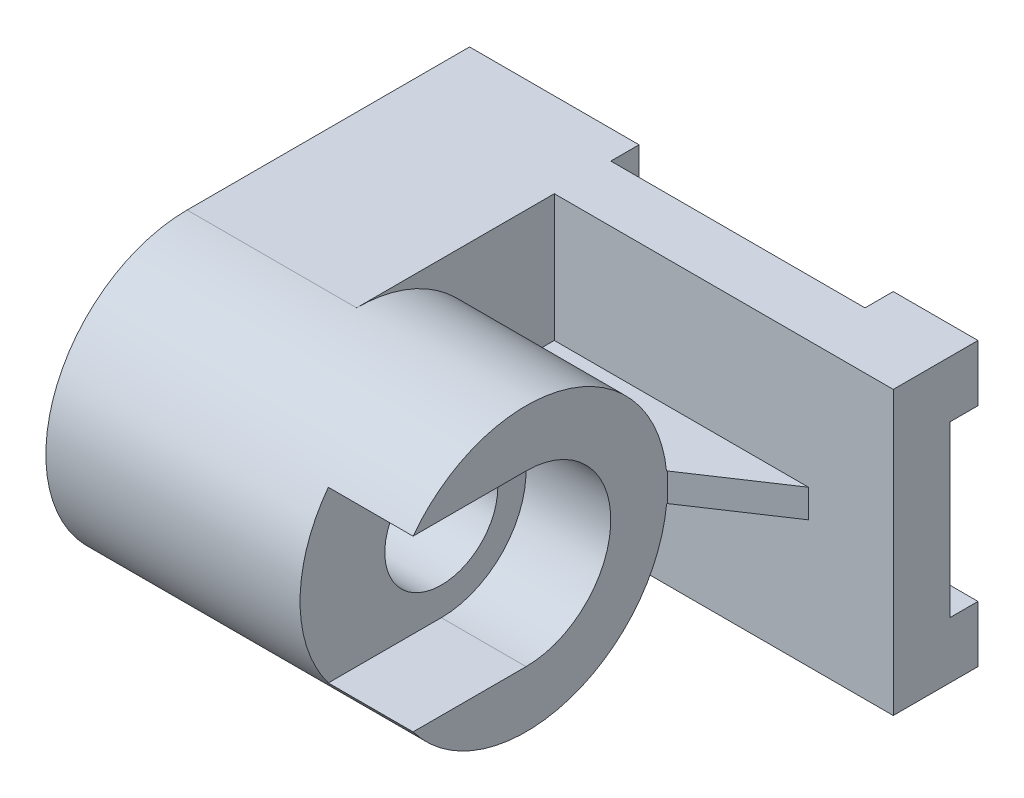
from build123d import *

# Parameters (mm, degrees)
BOSS_EXTRUDE1_DEPTH     = 18
SKETCH2_W               = 9
SKETCH2_H               = 1
CUT_EXTRUDE1_DEPTH      = 18
SKETCH3_R               = 2
CUT_EXTRUDE2_DEPTH      = 3
CUT_EXTRUDE3_DEPTH      = 3
CUT_EXTRUDE3_DEPTH_BACK = 6


with BuildPart() as part:
    # Sketch1 → Boss-Extrude1 (new body)
    with BuildSketch(Plane(origin=(0, 0, 0), x_dir=(0, 0, -1), z_dir=(1, 0, 0))):
        with BuildLine():
            ThreePointArc((-5, 5), (-10, 0), (-5, -5))
            Line((-5, -5), (-5, -2))
            ThreePointArc((-5, -2), (-7, 0), (-5, 2))
            Line((-5, 2), (-5, 5))
        make_face()
        with BuildLine():
            Line((-5, -2), (-5, -5))
            ThreePointArc((-5, -5), (-1.464466094, -3.535533906), (0, 0))
            ThreePointArc((0, 0), (-1.464466094, 3.535533906), (-5, 5))
            Line((-5, 5), (-5, 2))
            ThreePointArc((-5, 2), (-3.585786438, 1.414213562), (-3, 0))
            ThreePointArc((-3, 0), (-3.585786438, -1.414213562), (-5, -2))
        make_face()
        with BuildLine():
            ThreePointArc((-5, 5), (-10, 0), (-5, -5))
            Line((-5, -5), (-5, -2))
            ThreePointArc((-5, -2), (-7, 0), (-5, 2))
            Line((-5, 2), (-5, 5))
        make_face()
        with BuildLine():
            Line((-5, -2), (-5, -5))
            ThreePointArc((-5, -5), (-1.464466094, -3.535533906), (0, 0))
            ThreePointArc((0, 0), (-1.464466094, 3.535533906), (-5, 5))
            Line((-5, 5), (-5, 2))
            ThreePointArc((-5, 2), (-3.585786438, 1.414213562), (-3, 0))
            ThreePointArc((-3, 0), (-3.585786438, -1.414213562), (-5, -2))
        make_face()
        with BuildLine():
            Line((-5, -5), (5, -5))
            Line((5, -5), (5, -3))
            Line((5, -3), (4, -3))
            Line((4, -3), (4, 3))
            Line((4, 3), (5, 3))
            Line((5, 3), (5, 5))
            Line((5, 5), (-5, 5))
            ThreePointArc((-5, 5), (-1.464466094, 3.535533906), (0, 0))
            ThreePointArc((0, 0), (-1.464466094, -3.535533906), (-5, -5))
        make_face()
    extrude(amount=BOSS_EXTRUDE1_DEPTH)

    # Sketch2 → Cut-Extrude1 (cut)
    with BuildSketch(Plane.XZ.offset(5)):
        Polygon((9, 10), (9, 9), (12, 9), (12, 0), (15, -2), (18, -2), (18, 10), align=None)
        with Locations((10.5, -4.5)):
            Rectangle(SKETCH2_W, SKETCH2_H)
    extrude(amount=-CUT_EXTRUDE1_DEPTH, mode=Mode.SUBTRACT)

    # Sketch3 → Cut-Extrude2 (cut)
    with BuildSketch(Plane(origin=(12, 0, 0), x_dir=(0, 0, -1), z_dir=(1, 0, 0))):
        with BuildLine():
            Line((-9, -3), (-5, -3))
            ThreePointArc((-5, -3), (-2, 0), (-5, 3))
            Line((-5, 3), (-9, 3))
            Line((-9, 3), (-9, -3))
        make_face()
        with Locations((-5, 0)):
            Circle(SKETCH3_R, mode=Mode.SUBTRACT)
    extrude(amount=-CUT_EXTRUDE2_DEPTH, mode=Mode.SUBTRACT)

    # Sketch4 → Cut-Extrude3 (cut, two sides)
    with BuildSketch(Plane(origin=(12, 0, 0), x_dir=(0, 0, -1), z_dir=(1, 0, 0))) as cut_extrude3_sk:
        with BuildLine():
            Line((-0.025062814, 0.5), (2, 0.5))
            Line((2, 0.5), (2, 5))
            Line((2, 5), (-5, 5))
            ThreePointArc((-5, 5), (-1.645898034, 3.708099244), (-0.025062814, 0.5))
        make_face()
        with BuildLine():
            Line((-5, -5), (2, -5))
            Line((2, -5), (2, -0.5))
            Line((2, -0.5), (-0.025062814, -0.5))
            ThreePointArc((-0.025062814, -0.5), (-1.645898034, -3.708099244), (-5, -5))
        make_face()
    extrude(amount=CUT_EXTRUDE3_DEPTH, mode=Mode.SUBTRACT)
    extrude(cut_extrude3_sk.sketch, amount=-CUT_EXTRUDE3_DEPTH_BACK, mode=Mode.SUBTRACT)


solid = part.part
